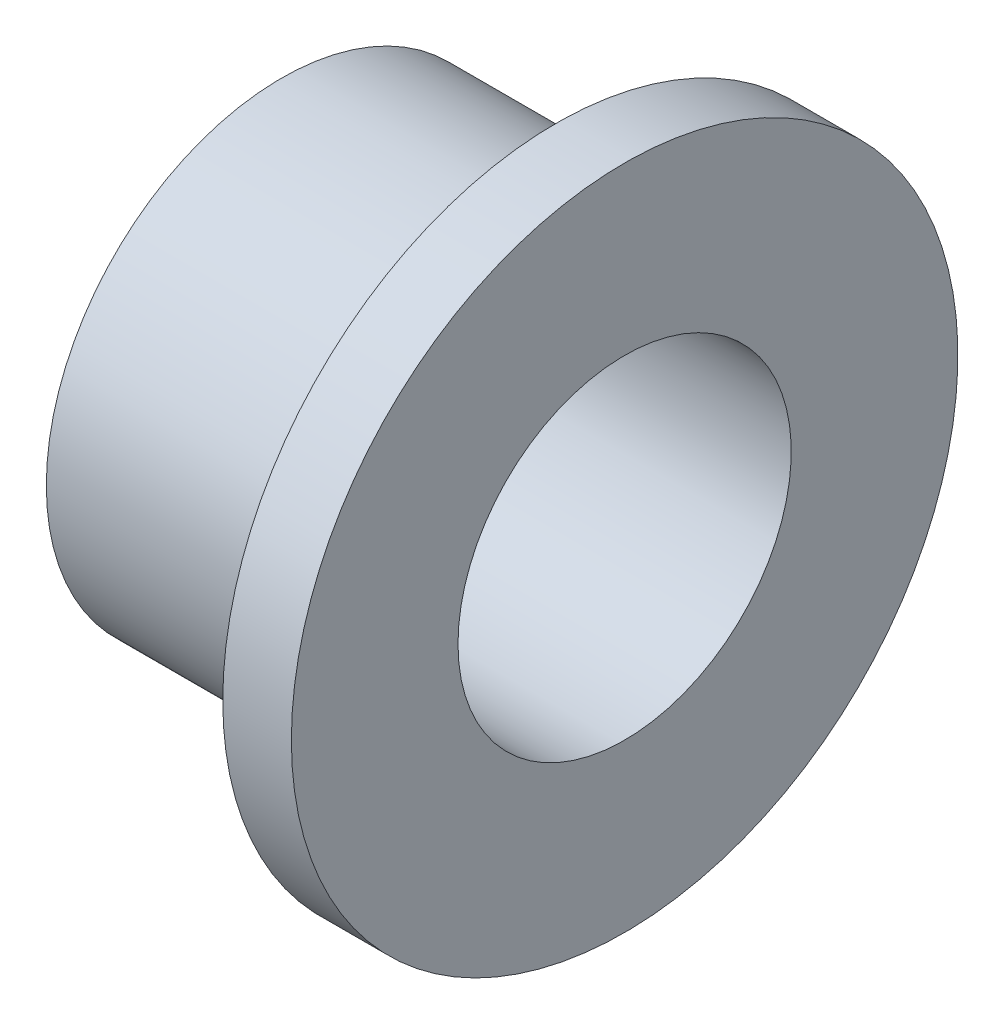
from build123d import *


with BuildPart() as part:
    # Sketch1 → Revolve1 (revolve)
    with BuildSketch(Plane(origin=(0, 0, 0), x_dir=(1, 0, 0), z_dir=(0, 1, 0))):
        Polygon((-30.174496644, -24), (-2.174496644, -24), (-2.174496644, -34), (4.825503356, -34), (4.825503356, -17), (-30.174496644, -17), align=None)
    revolve(axis=Axis((-56.375838926, 0, 0), (1, 0, 0)))


solid = part.part
